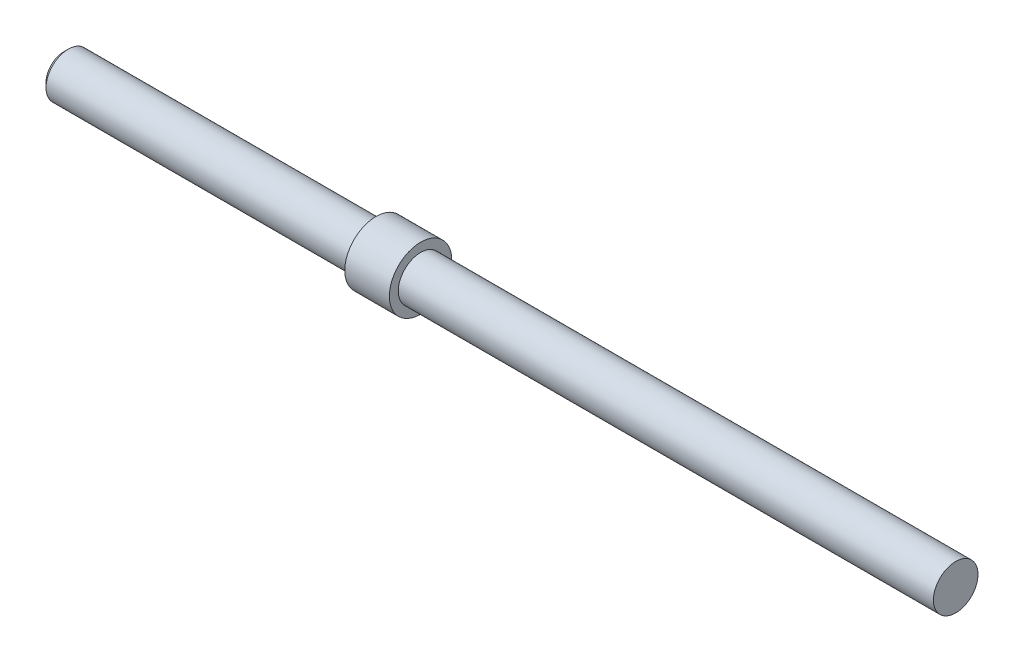
from build123d import *

# Parameters (mm, degrees)
SKETCH1_R           = 5
BOSS_EXTRUDE1_DEPTH = 200
CHAMFER1_SIZE       = 1
BOSS_EXTRUDE2_START = 70
SKETCH2_R           = 7
BOSS_EXTRUDE2_DEPTH = 10


with BuildPart() as part:
    # Sketch1 → Boss-Extrude1 (new body)
    with BuildSketch(Plane(origin=(0, 0, 0), x_dir=(0, 0, -1), z_dir=(1, 0, 0))):
        Circle(SKETCH1_R)
    extrude(amount=BOSS_EXTRUDE1_DEPTH)

    # Chamfer1
    chamfer1_edges = [part.edges().sort_by_distance(p)[0] for p in [
        (0, 0, 5),
    ]]
    chamfer(chamfer1_edges, length=CHAMFER1_SIZE)

    # Sketch2 → Boss-Extrude2 (add)
    with BuildSketch(Plane(origin=(0, 0, 0), x_dir=(0, 0, -1), z_dir=(1, 0, 0)).offset(BOSS_EXTRUDE2_START)):
        Circle(SKETCH2_R)
    extrude(amount=BOSS_EXTRUDE2_DEPTH)


solid = part.part
